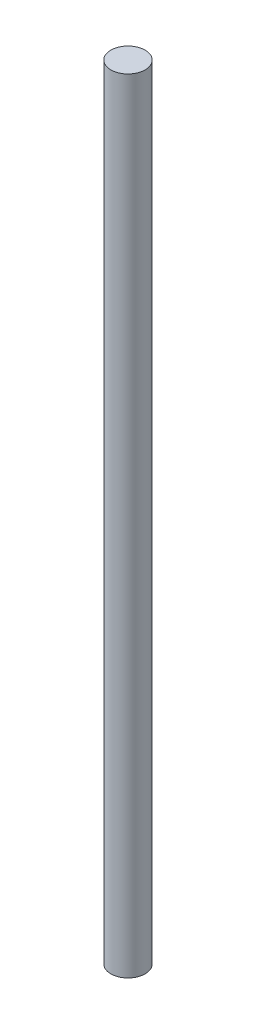
from build123d import *

# Parameters (mm, degrees)
SKETCH1_R           = 10
BOSS_EXTRUDE1_DEPTH = 457


with BuildPart() as part:
    # Sketch1 → Boss-Extrude1 (new body)
    with BuildSketch(Plane(origin=(0, 0, 0), x_dir=(1, 0, 0), z_dir=(0, 1, 0))):
        Circle(SKETCH1_R)
    extrude(amount=BOSS_EXTRUDE1_DEPTH)


solid = part.part
